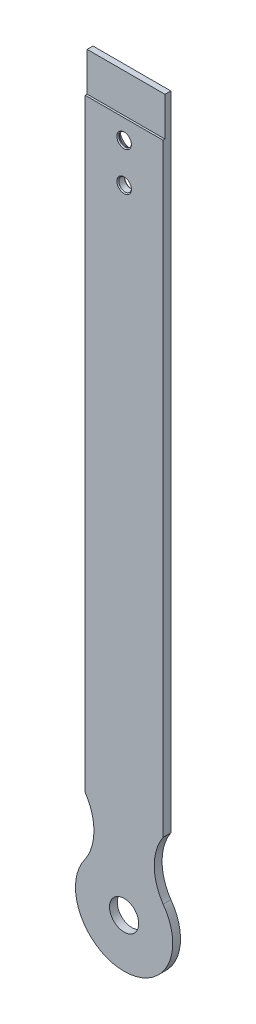
from build123d import *

# Parameters (mm, degrees)
SKETCH_1_R          = 3.25
SKETCH_1_R_2        = 7.5
EXTRUDE_1_DEPTH     = 4
SKETCH_2_W          = 1
SKETCH_2_H          = 19.943647813
CUT_EXTRUDE_1_DEPTH = 46
CHAMFER_1_SIZE      = 3
CHAMFER_2_SIZE      = 0.5


with BuildPart() as part:
    # Эскиз1 → Бобышка-Вытянуть1 (new body)
    with BuildSketch(Plane.XY):
        with BuildLine():
            Line((20, 69.629043508), (20, 400))
            Line((20, 400), (-20, 400))
            Line((-20, 400), (-20, 69.629043508))
            ThreePointArc((-20, 69.629043508), (-15.501661364, 54.765331367), (-20.05985163, 39.919864362))
            ThreePointArc((-20.05985163, 39.919864362), (0, 0), (20.05985163, 39.919864362))
            ThreePointArc((20.05985163, 39.919864362), (15.501661364, 54.765331367), (20, 69.629043508))
        make_face()
        with Locations((0, 370)):
            Circle(SKETCH_1_R, mode=Mode.SUBTRACT)
        with Locations((0, 350)):
            Circle(SKETCH_1_R, mode=Mode.SUBTRACT)
        with Locations((0, 25)):
            Circle(SKETCH_1_R_2, mode=Mode.SUBTRACT)
    extrude(amount=EXTRUDE_1_DEPTH)

    # Эскиз2 → Вырез-Вытянуть1 (cut, through all)
    with BuildSketch(Plane.ZY.offset(20)):
        with Locations((3.5, 390.028176094)):
            Rectangle(SKETCH_2_W, SKETCH_2_H)
    extrude(amount=-CUT_EXTRUDE_1_DEPTH, mode=Mode.SUBTRACT)

    # Фаска1
    chamfer_1_edges = [part.edges().sort_by_distance(p)[0] for p in [
        (-3.25, 370, 0),
    ]]
    chamfer(chamfer_1_edges, length=CHAMFER_1_SIZE)

    # Фаска2
    chamfer_2_edges = [part.edges().sort_by_distance(p)[0] for p in [
        (-3.25, 350, 0),
        (-3.25, 350, 4),
        (-3.25, 370, 4),
    ]]
    chamfer(chamfer_2_edges, length=CHAMFER_2_SIZE)


solid = part.part
